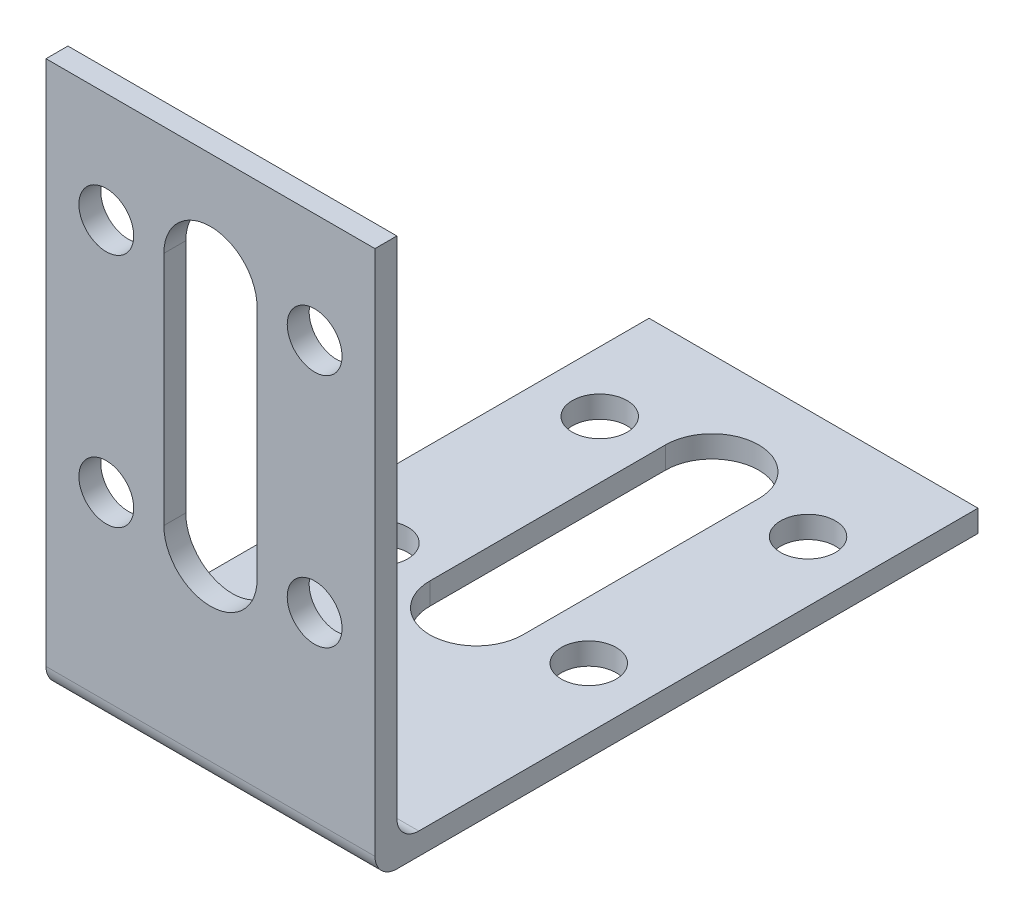
from build123d import *

# Parameters (mm, degrees)
BOSS_EXTRU_1_DEPTH      = 15
CONG_1_R                = 2
ENL_V_MAT_EXTRU_1_REACH = 4
ESQUISSE2_R             = 2.5
ENL_V_MAT_EXTRU_2_REACH = 4
ESQUISSE3_R             = 2.5


with BuildPart() as part:
    # Esquisse1 → Boss.-Extru.1 (new body, symmetric)
    with BuildSketch(Plane(origin=(0, 0, 0), x_dir=(0, 0, -1), z_dir=(1, 0, 0))):
        Polygon((0, 0), (0, 50), (2, 50), (2, 2), (55, 2), (55, 0), align=None)
    extrude(amount=BOSS_EXTRU_1_DEPTH, both=True)

    # Congé1
    cong_1_edges = [part.edges().sort_by_distance(p)[0] for p in [
        (0, 0, 0),
        (0, 2, -2),
    ]]
    fillet(cong_1_edges, radius=CONG_1_R)

    # Esquisse2 → Enlèv. mat.-Extru.1 (cut, up to next)
    with BuildSketch(Plane(origin=(0, 2, 0), x_dir=(1, 0, 0), z_dir=(0, 1, 0)), mode=Mode.PRIVATE) as enl_v_mat_extru_1_sk1:
        with BuildLine():
            Line((4.25, 24.25), (4.25, 45.75))
            ThreePointArc((4.25, 45.75), (0, 50), (-4.25, 45.75))
            Line((-4.25, 45.75), (-4.25, 24.25))
            ThreePointArc((-4.25, 24.25), (0, 20), (4.25, 24.25))
        make_face()
    enl_v_mat_extru_1_tool1 = extrude(enl_v_mat_extru_1_sk1.sketch, amount=-ENL_V_MAT_EXTRU_1_REACH, mode=Mode.PRIVATE) & part.part
    add(enl_v_mat_extru_1_tool1.solids().sort_by_distance((0, 2, -35))[0], mode=Mode.SUBTRACT)
    # Esquisse2 → Enlèv. mat.-Extru.1 (cut, up to next)
    with BuildSketch(Plane(origin=(0, 2, 0), x_dir=(1, 0, 0), z_dir=(0, 1, 0)), mode=Mode.PRIVATE) as enl_v_mat_extru_1_sk2:
        with Locations((-9.5, 25)):
            Circle(ESQUISSE2_R)
    enl_v_mat_extru_1_tool2 = extrude(enl_v_mat_extru_1_sk2.sketch, amount=-ENL_V_MAT_EXTRU_1_REACH, mode=Mode.PRIVATE) & part.part
    add(enl_v_mat_extru_1_tool2.solids().sort_by_distance((-9.5, 2, -25))[0], mode=Mode.SUBTRACT)
    # Esquisse2 → Enlèv. mat.-Extru.1 (cut, up to next)
    with BuildSketch(Plane(origin=(0, 2, 0), x_dir=(1, 0, 0), z_dir=(0, 1, 0)), mode=Mode.PRIVATE) as enl_v_mat_extru_1_sk3:
        with Locations((-9.5, 45)):
            Circle(ESQUISSE2_R)
    enl_v_mat_extru_1_tool3 = extrude(enl_v_mat_extru_1_sk3.sketch, amount=-ENL_V_MAT_EXTRU_1_REACH, mode=Mode.PRIVATE) & part.part
    add(enl_v_mat_extru_1_tool3.solids().sort_by_distance((-9.5, 2, -45))[0], mode=Mode.SUBTRACT)
    # Esquisse2 → Enlèv. mat.-Extru.1 (cut, up to next)
    with BuildSketch(Plane(origin=(0, 2, 0), x_dir=(1, 0, 0), z_dir=(0, 1, 0)), mode=Mode.PRIVATE) as enl_v_mat_extru_1_sk4:
        with Locations((9.5, 45)):
            Circle(ESQUISSE2_R)
    enl_v_mat_extru_1_tool4 = extrude(enl_v_mat_extru_1_sk4.sketch, amount=-ENL_V_MAT_EXTRU_1_REACH, mode=Mode.PRIVATE) & part.part
    add(enl_v_mat_extru_1_tool4.solids().sort_by_distance((9.5, 2, -45))[0], mode=Mode.SUBTRACT)
    # Esquisse2 → Enlèv. mat.-Extru.1 (cut, up to next)
    with BuildSketch(Plane(origin=(0, 2, 0), x_dir=(1, 0, 0), z_dir=(0, 1, 0)), mode=Mode.PRIVATE) as enl_v_mat_extru_1_sk5:
        with Locations((9.5, 25)):
            Circle(ESQUISSE2_R)
    enl_v_mat_extru_1_tool5 = extrude(enl_v_mat_extru_1_sk5.sketch, amount=-ENL_V_MAT_EXTRU_1_REACH, mode=Mode.PRIVATE) & part.part
    add(enl_v_mat_extru_1_tool5.solids().sort_by_distance((9.5, 2, -25))[0], mode=Mode.SUBTRACT)

    # Esquisse3 → Enlèv. mat.-Extru.2 (cut, up to next)
    with BuildSketch(Plane(origin=(0, 0, -2), x_dir=(-1, 0, 0), z_dir=(0, 0, -1)), mode=Mode.PRIVATE) as enl_v_mat_extru_2_sk1:
        with BuildLine():
            Line((-4.25, 40), (-4.25, 18.5))
            ThreePointArc((-4.25, 18.5), (0, 14.25), (4.25, 18.5))
            Line((4.25, 18.5), (4.25, 40))
            ThreePointArc((4.25, 40), (0, 44.25), (-4.25, 40))
        make_face()
    enl_v_mat_extru_2_tool1 = extrude(enl_v_mat_extru_2_sk1.sketch, amount=-ENL_V_MAT_EXTRU_2_REACH, mode=Mode.PRIVATE) & part.part
    add(enl_v_mat_extru_2_tool1.solids().sort_by_distance((0, 29.25, -2))[0], mode=Mode.SUBTRACT)
    # Esquisse3 → Enlèv. mat.-Extru.2 (cut, up to next)
    with BuildSketch(Plane(origin=(0, 0, -2), x_dir=(-1, 0, 0), z_dir=(0, 0, -1)), mode=Mode.PRIVATE) as enl_v_mat_extru_2_sk2:
        with Locations((-9.5, 40)):
            Circle(ESQUISSE3_R)
    enl_v_mat_extru_2_tool2 = extrude(enl_v_mat_extru_2_sk2.sketch, amount=-ENL_V_MAT_EXTRU_2_REACH, mode=Mode.PRIVATE) & part.part
    add(enl_v_mat_extru_2_tool2.solids().sort_by_distance((9.5, 40, -2))[0], mode=Mode.SUBTRACT)
    # Esquisse3 → Enlèv. mat.-Extru.2 (cut, up to next)
    with BuildSketch(Plane(origin=(0, 0, -2), x_dir=(-1, 0, 0), z_dir=(0, 0, -1)), mode=Mode.PRIVATE) as enl_v_mat_extru_2_sk3:
        with Locations((9.5, 40)):
            Circle(ESQUISSE3_R)
    enl_v_mat_extru_2_tool3 = extrude(enl_v_mat_extru_2_sk3.sketch, amount=-ENL_V_MAT_EXTRU_2_REACH, mode=Mode.PRIVATE) & part.part
    add(enl_v_mat_extru_2_tool3.solids().sort_by_distance((-9.5, 40, -2))[0], mode=Mode.SUBTRACT)
    # Esquisse3 → Enlèv. mat.-Extru.2 (cut, up to next)
    with BuildSketch(Plane(origin=(0, 0, -2), x_dir=(-1, 0, 0), z_dir=(0, 0, -1)), mode=Mode.PRIVATE) as enl_v_mat_extru_2_sk4:
        with Locations((9.5, 18.5)):
            Circle(ESQUISSE3_R)
    enl_v_mat_extru_2_tool4 = extrude(enl_v_mat_extru_2_sk4.sketch, amount=-ENL_V_MAT_EXTRU_2_REACH, mode=Mode.PRIVATE) & part.part
    add(enl_v_mat_extru_2_tool4.solids().sort_by_distance((-9.5, 18.5, -2))[0], mode=Mode.SUBTRACT)
    # Esquisse3 → Enlèv. mat.-Extru.2 (cut, up to next)
    with BuildSketch(Plane(origin=(0, 0, -2), x_dir=(-1, 0, 0), z_dir=(0, 0, -1)), mode=Mode.PRIVATE) as enl_v_mat_extru_2_sk5:
        with Locations((-9.5, 18.5)):
            Circle(ESQUISSE3_R)
    enl_v_mat_extru_2_tool5 = extrude(enl_v_mat_extru_2_sk5.sketch, amount=-ENL_V_MAT_EXTRU_2_REACH, mode=Mode.PRIVATE) & part.part
    add(enl_v_mat_extru_2_tool5.solids().sort_by_distance((9.5, 18.5, -2))[0], mode=Mode.SUBTRACT)


solid = part.part
